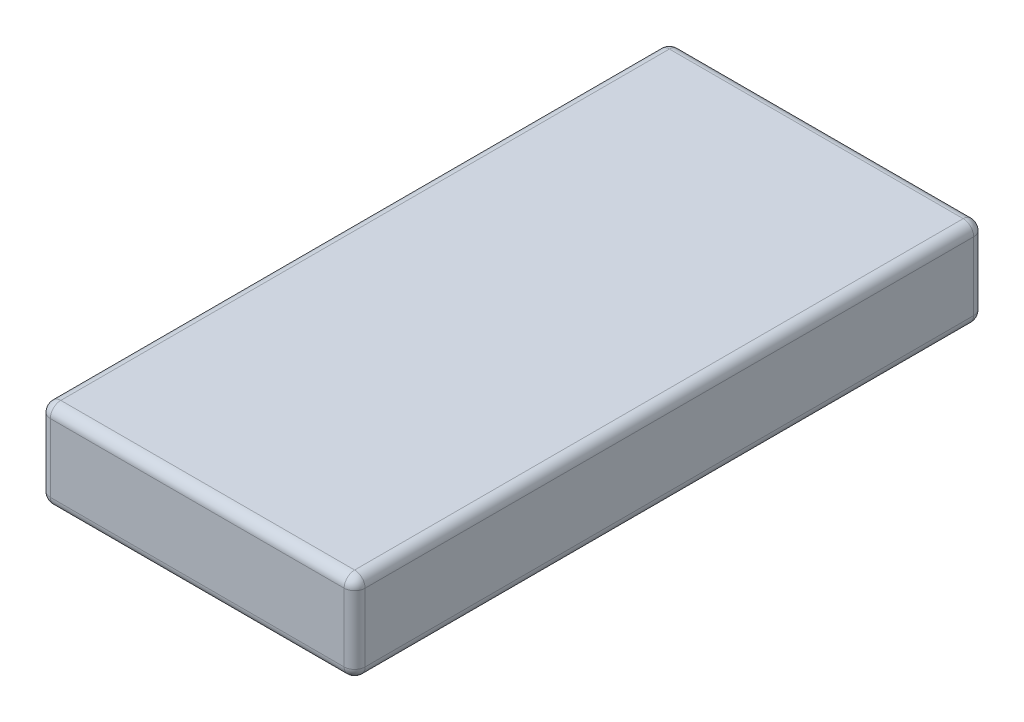
from build123d import *

# Parameters (mm, degrees)
ESQUISSE3_W        = 3
ESQUISSE3_H        = 6
BOSS_EXTRU_2_DEPTH = 0.85
CONG_2_R           = 0.1


with BuildPart() as part:
    # Esquisse3 → Boss.-Extru.2 (new body)
    with BuildSketch(Plane(origin=(0, 0, 0), x_dir=(1, 0, 0), z_dir=(0, 1, 0))):
        Rectangle(ESQUISSE3_W, ESQUISSE3_H)
    extrude(amount=BOSS_EXTRU_2_DEPTH)

    # Congé2
    cong_2_edges = [part.edges().sort_by_distance(p)[0] for p in [
        (1.5, 0.85, 0),
        (0, 0.85, -3),
        (-1.5, 0.85, 0),
        (0, 0, -3),
        (1.5, 0, 0),
        (0, 0, 3),
        (-1.5, 0, 0),
        (0, 0.85, 3),
        (-1.5, 0.425, -3),
        (1.5, 0.425, -3),
        (1.5, 0.425, 3),
        (-1.5, 0.425, 3),
    ]]
    fillet(cong_2_edges, radius=CONG_2_R)


solid = part.part
